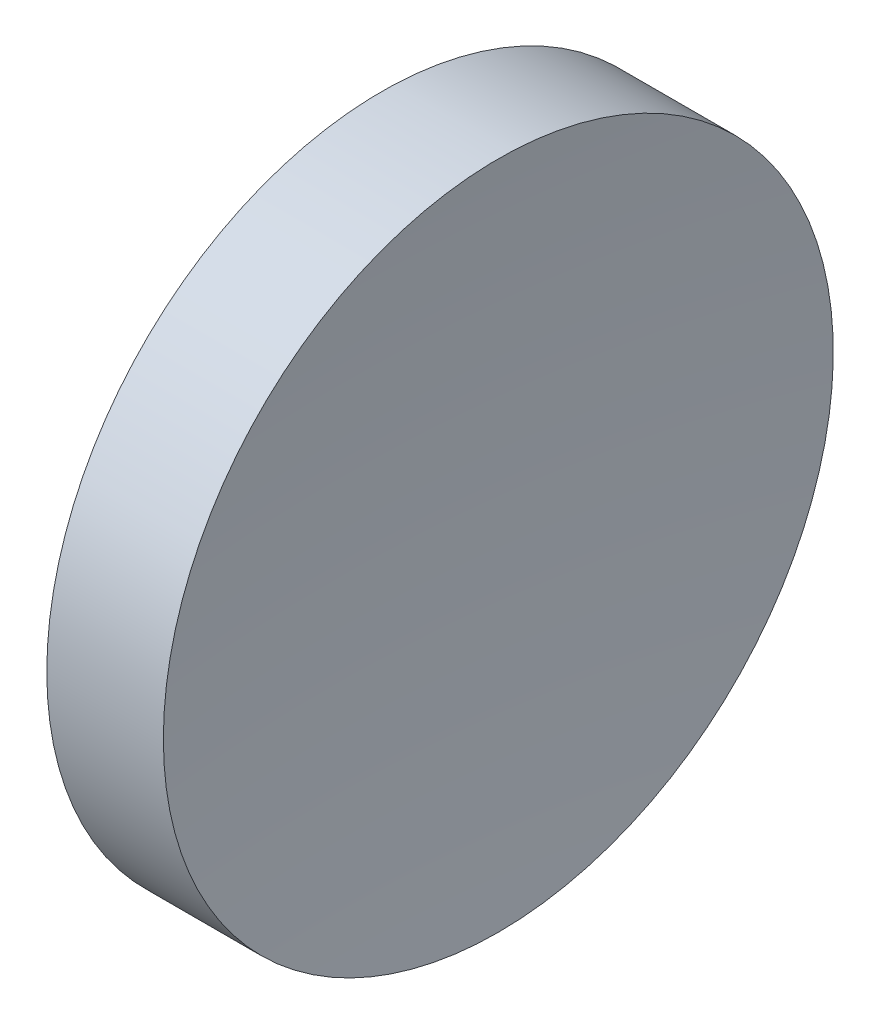
from build123d import *


with BuildPart() as part:
    # 草图1 → 旋转1 (revolve)
    with BuildSketch(Plane.XY, mode=Mode.PRIVATE) as revolve_1_sk:
        with BuildLine():
            Line((44.319585498, 26.089041149), (44.319585498, 31.089041149))
            Line((44.319585498, 31.089041149), (46.059585498, 31.089041149))
            ThreePointArc((46.059585498, 31.089041149), (45.879620104, 28.591919489), (45.819585612, 26.089041149))
            Line((45.819585612, 26.089041149), (44.319585498, 26.089041149))
        make_face()
    revolve(revolve_1_sk.sketch.rotate(Axis((42.449861114, 26.089041149, 0), (1, 0, 0)), 180), axis=Axis((42.449861114, 26.089041149, 0), (1, 0, 0)))  # turned: the seam where the file's is


solid = part.part
